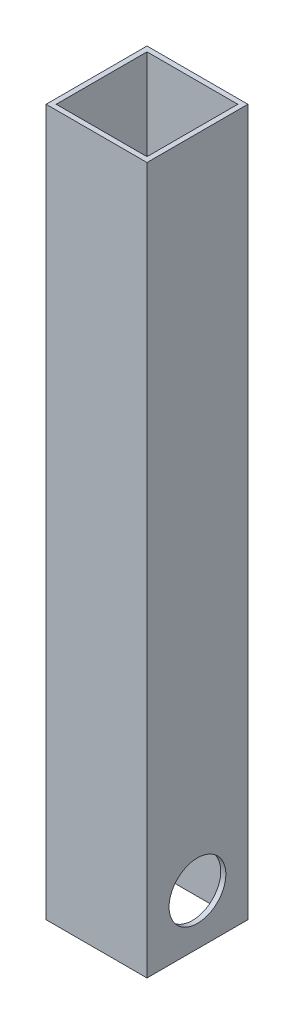
from build123d import *

# Parameters (mm, degrees)
SKETCH1_W           = 50.8
SKETCH1_H           = 50.8
SKETCH1_W_2         = 45.72
SKETCH1_H_2         = 45.72
BOSS_EXTRUDE1_DEPTH = 355.6
SKETCH2_R           = 14.2875
CUT_EXTRUDE1_DEPTH  = 50.8


with BuildPart() as part:
    # Sketch1 → Boss-Extrude1 (new body)
    with BuildSketch(Plane(origin=(0, 0, 0), x_dir=(1, 0, 0), z_dir=(0, 1, 0))):
        with Locations((25.4, -25.4)):
            Rectangle(SKETCH1_W, SKETCH1_H)
        with Locations((25.4, -25.4)):
            Rectangle(SKETCH1_W_2, SKETCH1_H_2, mode=Mode.SUBTRACT)
    extrude(amount=BOSS_EXTRUDE1_DEPTH)

    # Sketch2 → Cut-Extrude1 (cut)
    with BuildSketch(Plane.ZY):
        with Locations((25.4, 25.4)):
            Circle(SKETCH2_R)
    extrude(amount=-CUT_EXTRUDE1_DEPTH, mode=Mode.SUBTRACT)


solid = part.part
